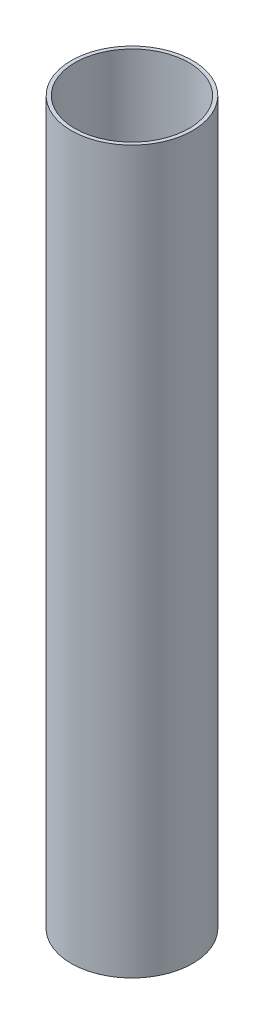
from build123d import *

# Parameters (mm, degrees)
SKETCH1_R           = 25
SKETCH1_R_2         = 23.5
BOSS_EXTRUDE1_DEPTH = 297


with BuildPart() as part:
    # Sketch1 → Boss-Extrude1 (new body)
    with BuildSketch(Plane(origin=(0, 0, 0), x_dir=(1, 0, 0), z_dir=(0, 1, 0))):
        Circle(SKETCH1_R)
        Circle(SKETCH1_R_2, mode=Mode.SUBTRACT)
    extrude(amount=BOSS_EXTRUDE1_DEPTH)


solid = part.part
